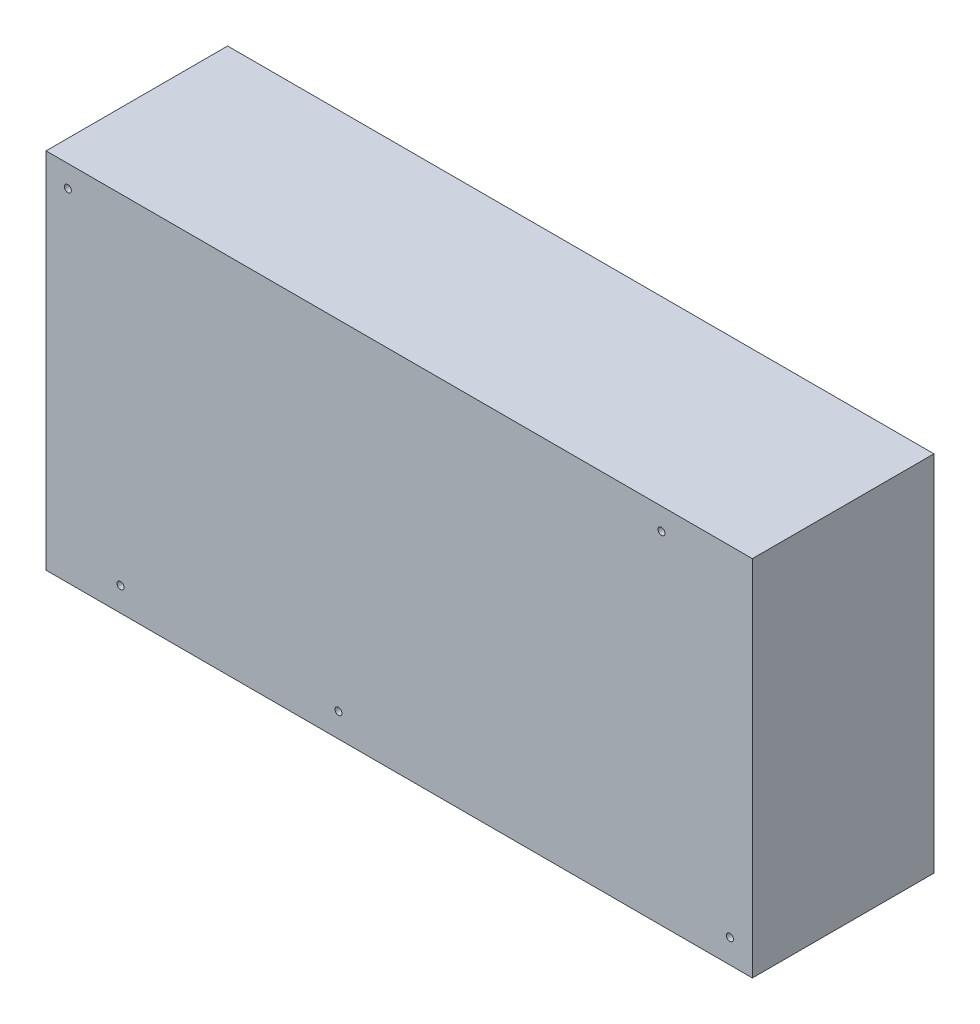
from build123d import *

# Parameters (mm, degrees)
SKETCH1_W                   = 247
SKETCH1_H                   = 127
BOSS_EXTRUDE1_DEPTH         = 63.5
F_41_0_096_DIAMETER_HOLE1_D = 2.4384


with BuildPart() as part:
    # Sketch1 → Boss-Extrude1 (new body)
    with BuildSketch(Plane.XY):
        Rectangle(SKETCH1_W, SKETCH1_H)
    extrude(amount=BOSS_EXTRUDE1_DEPTH)

    # #41 (0.096) Diameter Hole1 (through all)
    with Locations(Plane.XY.offset(63.5)):
        with Locations((-115.88, 55.88), (-97.465, -55.118), (-21.265, -55.118), (115.641, -55.118), (91.7015, 55.88)):
            Hole(F_41_0_096_DIAMETER_HOLE1_D / 2)


solid = part.part
